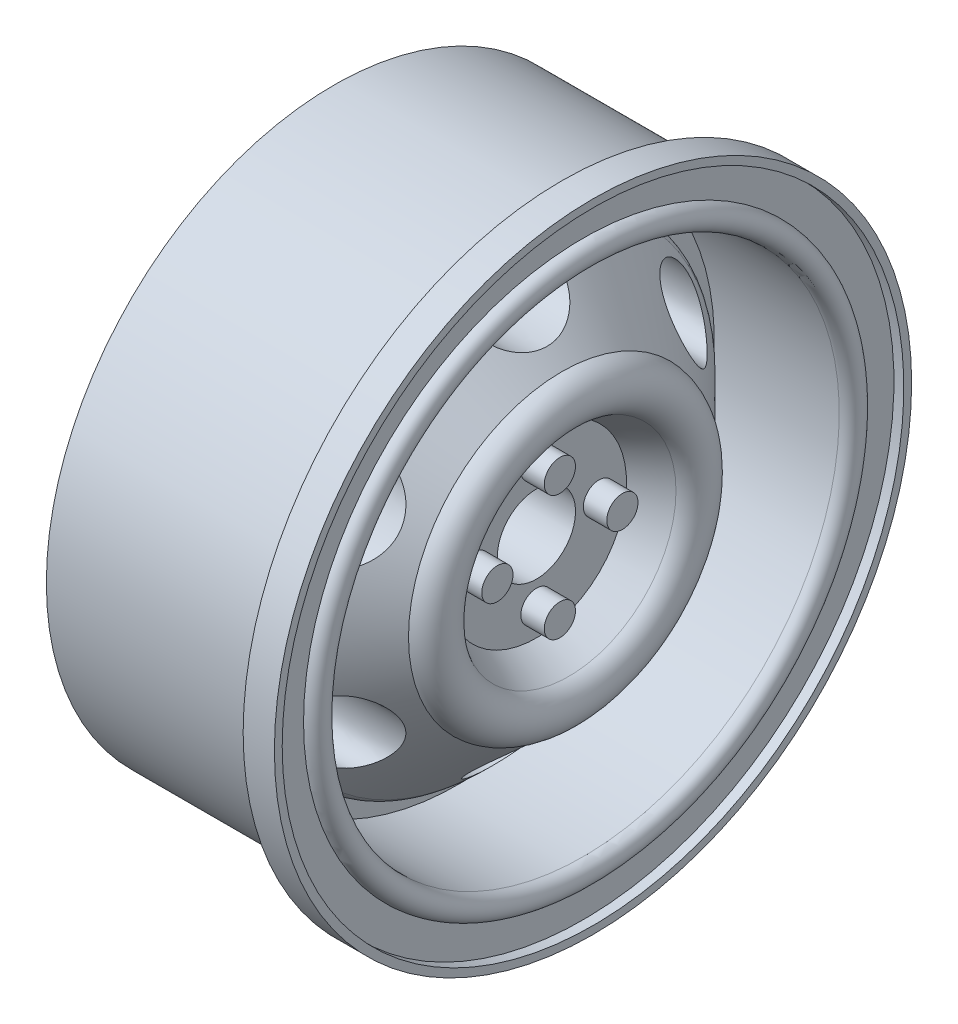
from build123d import *

# Parameters (mm, degrees)
SKETCH5_R               = 7.5
SKETCH5_R_2             = 5.75
BOSS_EXTRUDE2_DEPTH     = 5
SKETCH6_R               = 1
BOSS_EXTRUDE3_DEPTH     = 1.5
SKETCH7_RX              = 3
SKETCH7_RY              = 1.75
CUT_EXTRUDE1_DEPTH      = 4.737153187
CUT_EXTRUDE1_DEPTH_BACK = 14.012846913
FILLET1_R               = 1


with BuildPart() as part:
    # Sketch1 → Revolve1 (revolve)
    with BuildSketch(Plane(origin=(0, 0, 0), x_dir=(1, 0, 0), z_dir=(0, 1, 0))):
        with BuildLine():
            Line((15.965763544, 17.9), (15.965763544, 19.9))
            Line((15.965763544, 19.9), (16.6, 19.9))
            Line((16.6, 19.9), (16.6, 20.4))
            Line((16.6, 20.4), (16.1, 20.4))
            Line((16.1, 20.4), (14.6, 20.4))
            Line((14.6, 20.4), (14.6, 18.4))
            Line((14.6, 18.4), (0, 18.4))
            Line((0, 18.4), (0, 15.4))
            Line((0, 15.4), (4.965763544, 15.4))
            Line((4.965763544, 15.4), (4.965763544, 10.4))
            Line((4.965763544, 10.4), (4.965763544, 7.35))
            Line((4.965763544, 7.35), (4.965763544, 2.5))
            Line((4.965763544, 2.5), (11.317399503, 2.5))
            Line((11.317399503, 2.5), (12.978610458, 2.5))
            Line((12.978610458, 2.5), (12.978610458, 5.764604737))
            Line((12.978610458, 5.764604737), (15.049036265, 6.863458118))
            ThreePointArc((15.049036265, 6.863458118), (15.948142363, 8.509633809), (14.6, 9.813780408))
            Line((14.6, 9.813780408), (9.513780408, 14.9))
            Line((9.513780408, 14.9), (7.965763544, 14.9))
            Line((7.965763544, 14.9), (7.965763544, 16.4))
            Line((7.965763544, 16.4), (15.965763544, 16.4))
            ThreePointArc((15.965763544, 16.4), (16.715763544, 17.15), (15.965763544, 17.9))
        make_face()
    revolve(axis=Axis((-27.75, 0, 0), (1, 0, 0)))

    # Sketch5 → Boss-Extrude2 (add)
    with BuildSketch(Plane.ZY.offset(-4.965763544)):
        Circle(SKETCH5_R)
        Circle(SKETCH5_R_2, mode=Mode.SUBTRACT)
    extrude(amount=BOSS_EXTRUDE2_DEPTH)

    # Sketch6 → Boss-Extrude3 (add)
    with BuildSketch(Plane(origin=(12.978610458, 0, 0), x_dir=(0, 0, -1), z_dir=(1, 0, 0))):
        with Locations((0, 4.001760597)):
            Circle(SKETCH6_R)
        with Locations((4.001760597, 0)):
            Circle(SKETCH6_R)
        with Locations((0, -4.001760597)):
            Circle(SKETCH6_R)
        with Locations((-4.001760597, 0)):
            Circle(SKETCH6_R)
    extrude(amount=BOSS_EXTRUDE3_DEPTH)

    # Sketch7 → Cut-Extrude1 (cut, two sides)
    with BuildSketch(Plane(origin=(12.978610458, 0, 0), x_dir=(0, 0, -1), z_dir=(1, 0, 0))) as cut_extrude1_sk:
        with Locations((0, 12.5)):
            Ellipse(SKETCH7_RX, SKETCH7_RY)
        with Locations(Location((10.825317547, 6.25), (0, 0, 120))):
            Ellipse(SKETCH7_RX, SKETCH7_RY)
        with Locations(Location((10.825317547, -6.25), (0, 0, 60))):
            Ellipse(SKETCH7_RX, SKETCH7_RY)
        with Locations(Location((0, -12.5), (0, 0, 0))):
            Ellipse(SKETCH7_RX, SKETCH7_RY)
        with Locations(Location((-10.825317547, -6.25), (0, 0, -60))):
            Ellipse(SKETCH7_RX, SKETCH7_RY)
        with Locations(Location((-10.825317547, 6.25), (0, 0, -120))):
            Ellipse(SKETCH7_RX, SKETCH7_RY)
    extrude(amount=CUT_EXTRUDE1_DEPTH, mode=Mode.SUBTRACT)
    extrude(cut_extrude1_sk.sketch, amount=-CUT_EXTRUDE1_DEPTH_BACK, mode=Mode.SUBTRACT)

    # Fillet1
    fillet1_edges = [part.edges().sort_by_distance(p)[0] for p in [
        (9.513780408, 0, 14.9),
    ]]
    fillet(fillet1_edges, radius=FILLET1_R)


solid = part.part
